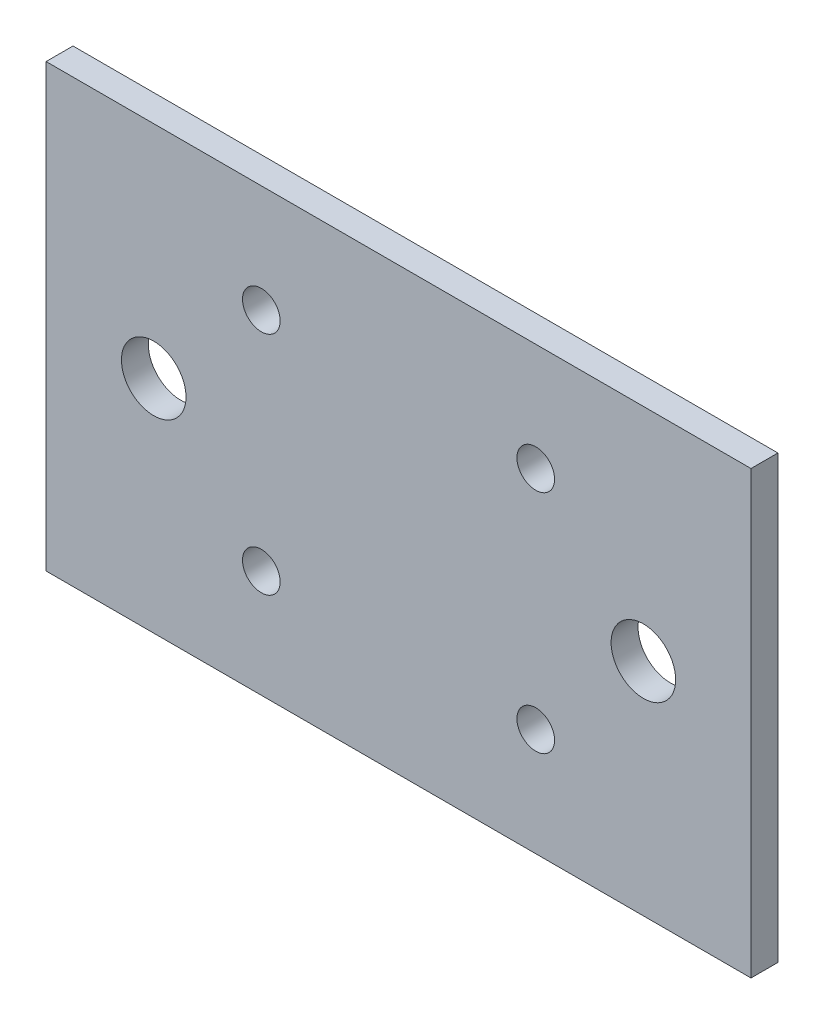
from build123d import *

# Parameters (mm, degrees)
SKETCH1_W           = 65.5
SKETCH1_H           = 41
SKETCH1_R           = 3
SKETCH1_R_2         = 1.75
BOSS_EXTRUDE1_DEPTH = 2.5


with BuildPart() as part:
    # Sketch1 → Boss-Extrude1 (new body)
    with BuildSketch(Plane.XY):
        Rectangle(SKETCH1_W, SKETCH1_H)
        with Locations((-22.75, 0)):
            Circle(SKETCH1_R, mode=Mode.SUBTRACT)
        with Locations((22.75, 0)):
            Circle(SKETCH1_R, mode=Mode.SUBTRACT)
        with Locations((-12.75, 10.5)):
            Circle(SKETCH1_R_2, mode=Mode.SUBTRACT)
        with Locations((12.75, 10.5)):
            Circle(SKETCH1_R_2, mode=Mode.SUBTRACT)
        with Locations((12.75, -10.5)):
            Circle(SKETCH1_R_2, mode=Mode.SUBTRACT)
        with Locations((-12.75, -10.5)):
            Circle(SKETCH1_R_2, mode=Mode.SUBTRACT)
    extrude(amount=BOSS_EXTRUDE1_DEPTH)


solid = part.part
